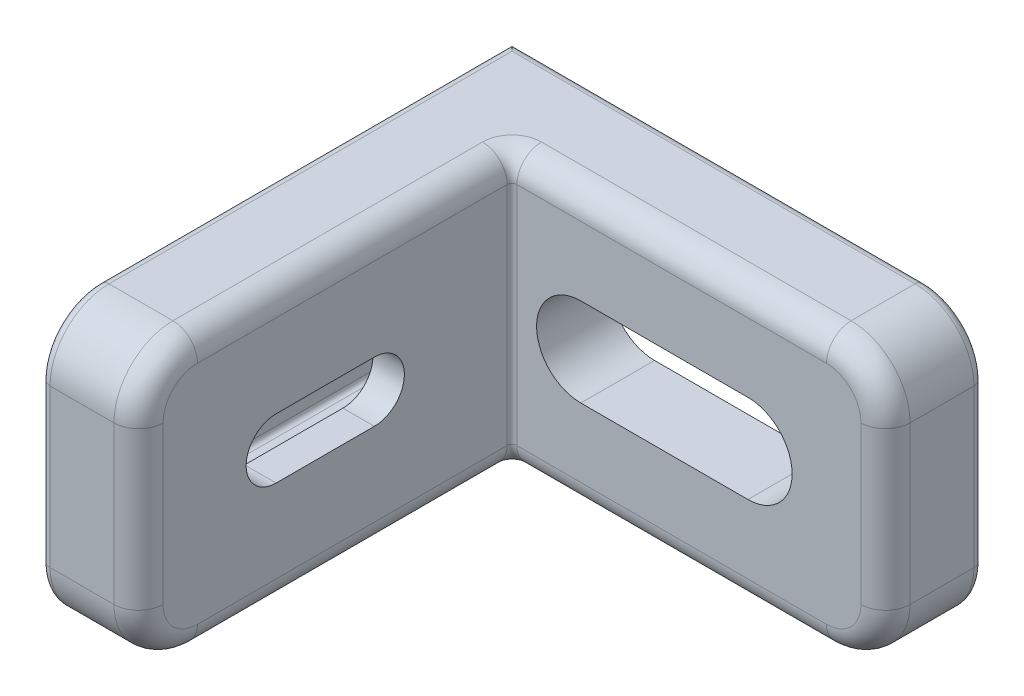
from build123d import *

# Parameters (mm, degrees)
SKETCH1_W           = 48
SKETCH1_H           = 48
BOSS_EXTRUDE1_DEPTH = 28
SKETCH2_W           = 38
SKETCH2_H           = 38
CUT_EXTRUDE1_DEPTH  = 29
SKETCH3_W           = 41
SKETCH3_H           = 16.4
CUT_EXTRUDE2_DEPTH  = 2.5
SKETCH4_W           = 3.6
SKETCH4_H           = 10.7
CUT_EXTRUDE3_DEPTH  = 38.5
CUT_EXTRUDE4_REACH  = 50
CUT_EXTRUDE5_DEPTH  = 42.2
CUT_EXTRUDE6_DEPTH  = 46.5
FILLET1_R           = 6
FILLET2_R           = 0.5
FILLET3_R           = 1
FILLET4_R           = 2.5


with BuildPart() as part:
    # Sketch1 → Boss-Extrude1 (new body)
    with BuildSketch(Plane(origin=(0, 28, 0), x_dir=(1, 0, 0), z_dir=(0, 1, 0))):
        with Locations((24, -24)):
            Rectangle(SKETCH1_W, SKETCH1_H)
    extrude(amount=-BOSS_EXTRUDE1_DEPTH)

    # Sketch2 → Cut-Extrude1 (cut, through all)
    with BuildSketch(Plane(origin=(0, 28, 0), x_dir=(-1, 0, 0), z_dir=(0, 1, 0))):
        with Locations((-29, 29)):
            Rectangle(SKETCH2_W, SKETCH2_H)
    extrude(amount=-CUT_EXTRUDE1_DEPTH, mode=Mode.SUBTRACT)

    # Sketch3 → Cut-Extrude2 (cut)
    with BuildSketch(Plane(origin=(0, 0, 0), x_dir=(-1, 0, 0), z_dir=(0, 0, -1))):
        with Locations((-20.5, 14)):
            Rectangle(SKETCH3_W, SKETCH3_H)
    extrude(amount=-CUT_EXTRUDE2_DEPTH, mode=Mode.SUBTRACT)

    # Sketch4 → Cut-Extrude3 (cut)
    with BuildSketch(Plane(origin=(0, 0, 2.5), x_dir=(-1, 0, 0), z_dir=(0, 0, -1))):
        with Locations((-5, 14)):
            Rectangle(SKETCH4_W, SKETCH4_H)
    extrude(amount=-CUT_EXTRUDE3_DEPTH, mode=Mode.SUBTRACT)

    # Sketch5 → Cut-Extrude4 (cut, up to next)
    with BuildSketch(Plane.ZY, mode=Mode.PRIVATE) as cut_extrude4_sk1:
        with BuildLine():
            Line((2.5, 17.05), (2.5, 10.95))
            Line((2.5, 10.95), (34, 10.95))
            ThreePointArc((34, 10.95), (37.05, 14), (34, 17.05))
            Line((34, 17.05), (2.5, 17.05))
        make_face()
    cut_extrude4_tool1 = extrude(cut_extrude4_sk1.sketch, amount=-CUT_EXTRUDE4_REACH, mode=Mode.PRIVATE) & part.part
    add(cut_extrude4_tool1.solids().sort_by_distance((0, 14, 19.454568))[0], mode=Mode.SUBTRACT)

    # Sketch6 → Cut-Extrude5 (cut, through all)
    with BuildSketch(Plane.ZY.offset(-6.8)):
        with BuildLine():
            Line((34, 17.05), (24, 17.05))
            ThreePointArc((24, 17.05), (20.95, 14), (24, 10.95))
            Line((24, 10.95), (34, 10.95))
            ThreePointArc((34, 10.95), (37.05, 14), (34, 17.05))
        make_face()
    extrude(amount=-CUT_EXTRUDE5_DEPTH, mode=Mode.SUBTRACT)

    # Sketch7 → Cut-Extrude6 (cut, through all)
    with BuildSketch(Plane(origin=(0, 0, 2.5), x_dir=(-1, 0, 0), z_dir=(0, 0, -1))):
        with BuildLine():
            Line((-17, 18.5), (-34, 18.5))
            ThreePointArc((-34, 18.5), (-38.5, 14), (-34, 9.5))
            Line((-34, 9.5), (-17, 9.5))
            ThreePointArc((-17, 9.5), (-12.5, 14), (-17, 18.5))
        make_face()
    extrude(amount=-CUT_EXTRUDE6_DEPTH, mode=Mode.SUBTRACT)

    # Fillet1
    fillet1_edges = [part.edges().sort_by_distance(p)[0] for p in [
        (48, 28, 5),
        (48, 0, 5),
        (5, 28, 48),
        (5, 0, 48),
    ]]
    fillet(fillet1_edges, radius=FILLET1_R)

    # Fillet2
    fillet2_edges = [part.edges().sort_by_distance(p)[0] for p in [
        (10, 14, 10),
        (6.8, 8.65, 21.75),
        (6.8, 19.35, 21.75),
        (3.2, 8.65, 21.75),
    ]]
    fillet(fillet2_edges, radius=FILLET2_R)

    # Fillet3
    fillet3_edges = [part.edges().sort_by_distance(p)[0] for p in [
        (0, 14, 48),
        (21, 0, 0),
        (0, 26.242640687, 46.242640687),
        (0, 1.757359313, 46.242640687),
        (21, 28, 0),
        (48, 14, 0),
        (46.242640687, 26.242640687, 0),
        (46.242640687, 1.757359313, 0),
        (0, 0, 21),
        (0, 28, 21),
    ]]
    fillet(fillet3_edges, radius=FILLET3_R)

    # Fillet4
    fillet4_edges = [part.edges().sort_by_distance(p)[0] for p in [
        (10, 14, 48),
        (10, 26.242640687, 46.242640687),
        (10, 1.757359313, 46.242640687),
        (26.25, 0, 10),
        (26.25, 28, 10),
        (48, 14, 10),
        (46.242640687, 26.242640687, 10),
        (46.242640687, 1.757359313, 10),
        (10, 0, 26.25),
        (10, 28, 26.25),
        (10.146446609, 28, 10.146446609),
        (10.146446609, 0, 10.146446609),
    ]]
    fillet(fillet4_edges, radius=FILLET4_R)


solid = part.part
